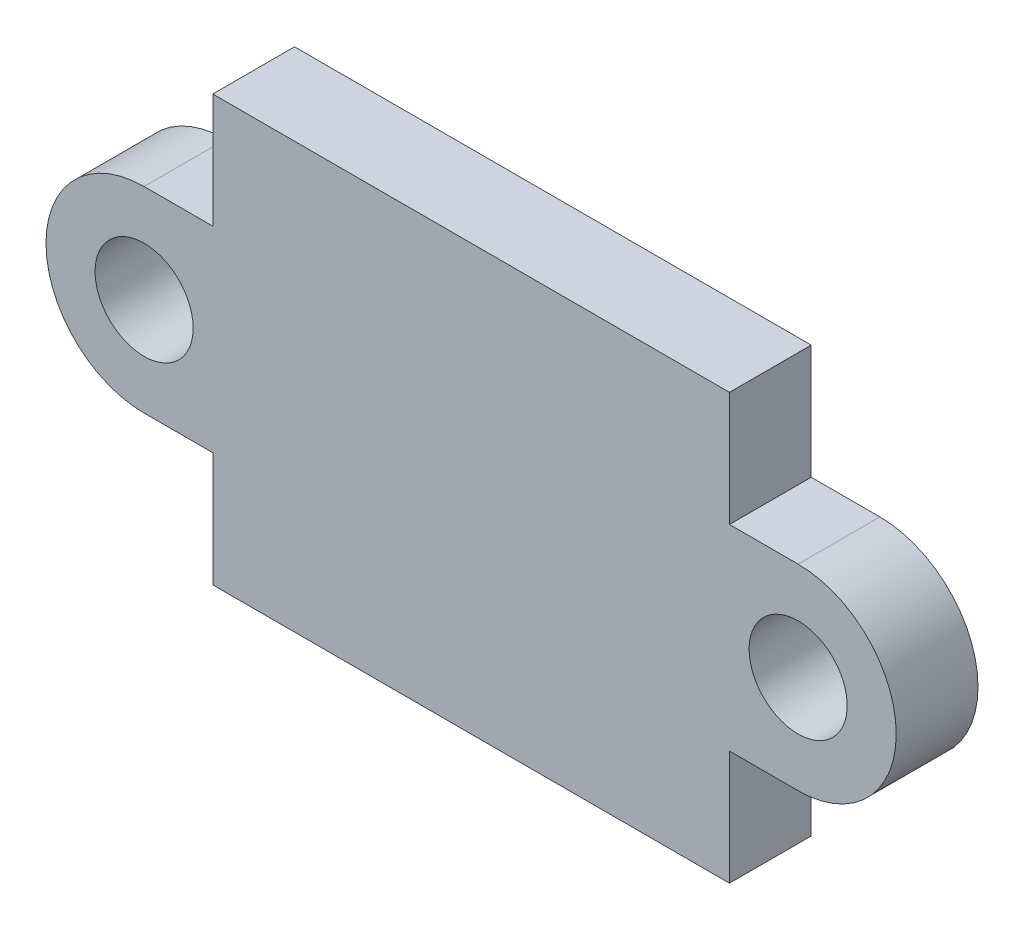
from build123d import *

# Parameters (mm, degrees)
ESBO_O1_R                = 1.5
RESSALTO_EXTRUS_O1_DEPTH = 2.5


with BuildPart() as part:
    # Esboço1 → Ressalto-extrusão1 (new body)
    with BuildSketch(Plane.XY):
        with BuildLine():
            Line((-10, 3), (-7.9, 3))
            Line((-7.9, 3), (-7.9, 6.5))
            Line((-7.9, 6.5), (7.9, 6.5))
            Line((7.9, 6.5), (7.9, 3))
            Line((7.9, 3), (10, 3))
            ThreePointArc((10, 3), (13, 0), (10, -3))
            Line((10, -3), (7.9, -3))
            Line((7.9, -3), (7.9, -6.5))
            Line((7.9, -6.5), (-7.9, -6.5))
            Line((-7.9, -6.5), (-7.9, -3))
            Line((-7.9, -3), (-10, -3))
            ThreePointArc((-10, -3), (-13, 0), (-10, 3))
        make_face()
        with Locations((-10, 0)):
            Circle(ESBO_O1_R, mode=Mode.SUBTRACT)
        with Locations((10, 0)):
            Circle(ESBO_O1_R, mode=Mode.SUBTRACT)
    extrude(amount=RESSALTO_EXTRUS_O1_DEPTH)


solid = part.part
